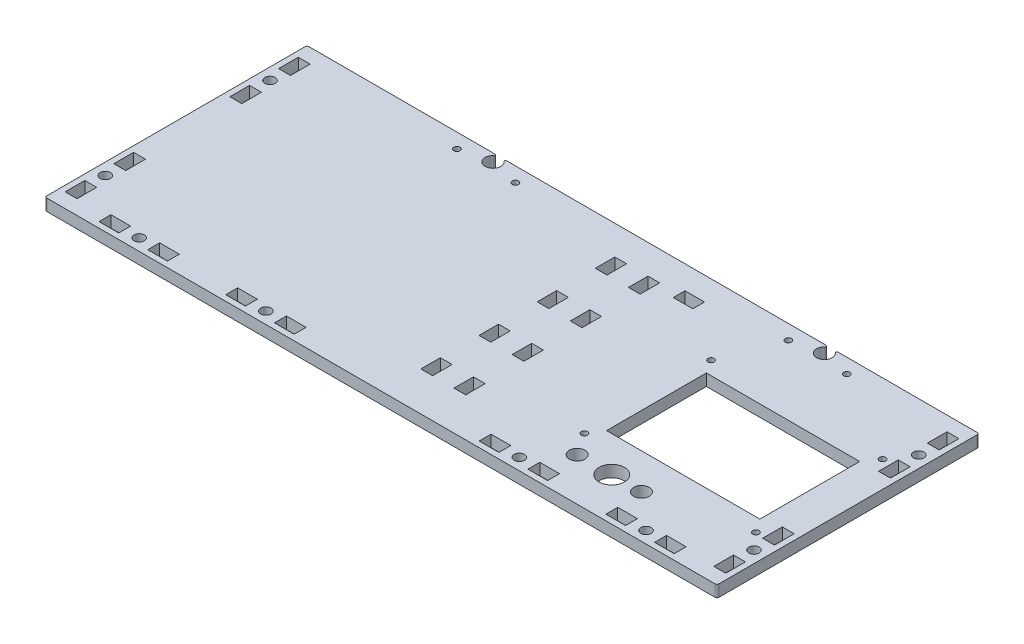
from build123d import *

# Parameters (mm, degrees)
SKETCH1_W                = 344.8
SKETCH1_H                = 134.5
BOSS_EXTRUDE1_DEPTH      = 6
SKETCH2_R                = 6.5
SKETCH2_R_2              = 4
SKETCH2_W                = 78.65
SKETCH2_H                = 51.2
CUT_EXTRUDE1_DEPTH       = 7
M3_CLEARANCE_HOLE1_D     = 3.2
M5_CLEARANCE_HOLE1_D     = 5.3
SKETCH7_W                = 6.1
SKETCH7_H                = 10.1
CUT_EXTRUDE2_DEPTH       = 4
CUT_EXTRUDE2_DEPTH_BACK  = 4
SKETCH71_W               = 6.1
SKETCH71_H               = 10.1
CUT_EXTRUDE21_DEPTH      = 4
CUT_EXTRUDE21_DEPTH_BACK = 4
SKETCH72_W               = 6.1
SKETCH72_H               = 10.1
CUT_EXTRUDE22_DEPTH      = 4
CUT_EXTRUDE22_DEPTH_BACK = 4
SKETCH73_W               = 6.1
SKETCH73_H               = 10.1
CUT_EXTRUDE23_DEPTH      = 4
CUT_EXTRUDE23_DEPTH_BACK = 4
SKETCH74_W               = 6.1
SKETCH74_H               = 10.1
CUT_EXTRUDE24_DEPTH      = 4
CUT_EXTRUDE24_DEPTH_BACK = 4
SKETCH75_W               = 6.1
SKETCH75_H               = 10.1
CUT_EXTRUDE25_DEPTH      = 4
CUT_EXTRUDE25_DEPTH_BACK = 4
SKETCH77_W               = 6.1
SKETCH77_H               = 10.1
CUT_EXTRUDE27_DEPTH      = 4
CUT_EXTRUDE27_DEPTH_BACK = 4
SKETCH78_W               = 6.1
SKETCH78_H               = 10.1
CUT_EXTRUDE28_DEPTH      = 4
CUT_EXTRUDE28_DEPTH_BACK = 4
CUT_EXTRUDE29_DEPTH      = 7
SKETCH62_W               = 10
SKETCH62_H               = 6
CUT_EXTRUDE12_DEPTH      = 4
SKETCH63_W               = 10
SKETCH63_H               = 6
CUT_EXTRUDE13_DEPTH      = 4
SKETCH64_W               = 10
SKETCH64_H               = 6
CUT_EXTRUDE14_DEPTH      = 4
SKETCH65_W               = 10
SKETCH65_H               = 6
CUT_EXTRUDE15_DEPTH      = 4
SKETCH81_R               = 2.65
BOSS_EXTRUDE2_DEPTH      = 6
SKETCH67_W               = 10
SKETCH67_H               = 6
CUT_EXTRUDE17_DEPTH      = 4
CUT_EXTRUDE17_DEPTH_BACK = 4
M3_CLEARANCE_HOLE2_D     = 3.2
FILLET1_R                = 1


with BuildPart() as part:
    # Sketch1 → Boss-Extrude1 (new body)
    with BuildSketch(Plane(origin=(0, 0, 0), x_dir=(1, 0, 0), z_dir=(0, 1, 0))):
        Rectangle(SKETCH1_W, SKETCH1_H)
    extrude(amount=BOSS_EXTRUDE1_DEPTH)

    # Sketch2 → Cut-Extrude1 (cut, through all)
    with BuildSketch(Plane(origin=(0, 0, 0), x_dir=(-1, 0, 0), z_dir=(0, -1, 0))):
        with Locations((-96.4, -45.25)):
            Circle(SKETCH2_R)
        with Locations((-78.65, -45.25)):
            Circle(SKETCH2_R_2)
        with Locations((-111.65, -45.25)):
            Circle(SKETCH2_R_2)
        with Locations((-114.825, -1.4)):
            Rectangle(SKETCH2_W, SKETCH2_H)
    extrude(amount=-CUT_EXTRUDE1_DEPTH, mode=Mode.SUBTRACT)

    # M3 Clearance Hole1 (through all)
    with Locations(Plane(origin=(0, 0, 0), x_dir=(-1, 0, 0), z_dir=(0, -1, 0))):
        with Locations((-159, 31.1), (-71.05, 31.1), (-71.05, -33.9), (-159, -33.9)):
            Hole(M3_CLEARANCE_HOLE1_D / 2)

    # M5 Clearance Hole1 (through all)
    with Locations(Plane(origin=(0, 0, 0), x_dir=(-1, 0, 0), z_dir=(0, -1, 0))):
        with Locations((0, -61.25), (65, -61.25), (130, -61.25), (-166.4, -42.25), (-166.4, 42.25)):
            m5_clearance_hole1 = Hole(M5_CLEARANCE_HOLE1_D / 2)

    # Mirror1: M5 Clearance Hole1 across plane
    add(m5_clearance_hole1.mirror(Plane(origin=(0, 0, 0), x_dir=(0, 0, 1), z_dir=(1, 0, 0))), mode=Mode.SUBTRACT)

    # Sketch7 → Cut-Extrude2 (cut, two sides)
    with BuildSketch(Plane(origin=(122.4, 3, -22.25), x_dir=(1, 0, 0), z_dir=(0, -1, 0))) as cut_extrude2_sk:
        with Locations((44, -32.5)):
            Rectangle(SKETCH7_W, SKETCH7_H)
        with Locations((44, -7.5)):
            Rectangle(SKETCH7_W, SKETCH7_H)
    extrude(amount=CUT_EXTRUDE2_DEPTH, mode=Mode.SUBTRACT)
    extrude(cut_extrude2_sk.sketch, amount=-CUT_EXTRUDE2_DEPTH_BACK, mode=Mode.SUBTRACT)

    # Sketch71 → Cut-Extrude21 (cut, two sides)
    with BuildSketch(Plane(origin=(122.4, 3, 62.25), x_dir=(1, 0, 0), z_dir=(0, -1, 0))) as cut_extrude21_sk:
        with Locations((44, -32.5)):
            Rectangle(SKETCH71_W, SKETCH71_H)
        with Locations((44, -7.5)):
            Rectangle(SKETCH71_W, SKETCH71_H)
    extrude(amount=CUT_EXTRUDE21_DEPTH, mode=Mode.SUBTRACT)
    extrude(cut_extrude21_sk.sketch, amount=-CUT_EXTRUDE21_DEPTH_BACK, mode=Mode.SUBTRACT)

    # Sketch72 → Cut-Extrude22 (cut, two sides)
    with BuildSketch(Plane(origin=(-210.4, 3, -22.25), x_dir=(1, 0, 0), z_dir=(0, -1, 0))) as cut_extrude22_sk:
        with Locations((44, -32.5)):
            Rectangle(SKETCH72_W, SKETCH72_H)
        with Locations((44, -7.5)):
            Rectangle(SKETCH72_W, SKETCH72_H)
    extrude(amount=CUT_EXTRUDE22_DEPTH, mode=Mode.SUBTRACT)
    extrude(cut_extrude22_sk.sketch, amount=-CUT_EXTRUDE22_DEPTH_BACK, mode=Mode.SUBTRACT)

    # Sketch73 → Cut-Extrude23 (cut, two sides)
    with BuildSketch(Plane(origin=(-210.4, 3, 62.25), x_dir=(1, 0, 0), z_dir=(0, -1, 0))) as cut_extrude23_sk:
        with Locations((44, -32.5)):
            Rectangle(SKETCH73_W, SKETCH73_H)
        with Locations((44, -7.5)):
            Rectangle(SKETCH73_W, SKETCH73_H)
    extrude(amount=CUT_EXTRUDE23_DEPTH, mode=Mode.SUBTRACT)
    extrude(cut_extrude23_sk.sketch, amount=-CUT_EXTRUDE23_DEPTH_BACK, mode=Mode.SUBTRACT)

    # Sketch74 → Cut-Extrude24 (cut, two sides)
    with BuildSketch(Plane(origin=(150, 3, 105.25), x_dir=(0, 0, -1), z_dir=(0, -1, 0))) as cut_extrude24_sk:
        with Locations((44, -32.5)):
            Rectangle(SKETCH74_W, SKETCH74_H)
        with Locations((44, -7.5)):
            Rectangle(SKETCH74_W, SKETCH74_H)
    extrude(amount=CUT_EXTRUDE24_DEPTH, mode=Mode.SUBTRACT)
    extrude(cut_extrude24_sk.sketch, amount=-CUT_EXTRUDE24_DEPTH_BACK, mode=Mode.SUBTRACT)

    # Sketch75 → Cut-Extrude25 (cut, two sides)
    with BuildSketch(Plane(origin=(45, 3, 17.25), x_dir=(0, 0, 1), z_dir=(0, -1, 0))) as cut_extrude25_sk:
        with Locations((44, -32.5)):
            Rectangle(SKETCH75_W, SKETCH75_H)
        with Locations((44, -7.5)):
            Rectangle(SKETCH75_W, SKETCH75_H)
    extrude(amount=CUT_EXTRUDE25_DEPTH, mode=Mode.SUBTRACT)
    extrude(cut_extrude25_sk.sketch, amount=-CUT_EXTRUDE25_DEPTH_BACK, mode=Mode.SUBTRACT)

    # Sketch77 → Cut-Extrude27 (cut, two sides)
    with BuildSketch(Plane(origin=(-85, 3, 17.25), x_dir=(0, 0, 1), z_dir=(0, -1, 0))) as cut_extrude27_sk:
        with Locations((44, -32.5)):
            Rectangle(SKETCH77_W, SKETCH77_H)
        with Locations((44, -7.5)):
            Rectangle(SKETCH77_W, SKETCH77_H)
    extrude(amount=CUT_EXTRUDE27_DEPTH, mode=Mode.SUBTRACT)
    extrude(cut_extrude27_sk.sketch, amount=-CUT_EXTRUDE27_DEPTH_BACK, mode=Mode.SUBTRACT)

    # Sketch78 → Cut-Extrude28 (cut, two sides)
    with BuildSketch(Plane(origin=(-150, 3, 17.25), x_dir=(0, 0, 1), z_dir=(0, -1, 0))) as cut_extrude28_sk:
        with Locations((44, -32.5)):
            Rectangle(SKETCH78_W, SKETCH78_H)
        with Locations((44, -7.5)):
            Rectangle(SKETCH78_W, SKETCH78_H)
    extrude(amount=CUT_EXTRUDE28_DEPTH, mode=Mode.SUBTRACT)
    extrude(cut_extrude28_sk.sketch, amount=-CUT_EXTRUDE28_DEPTH_BACK, mode=Mode.SUBTRACT)

    # Sketch79 → Cut-Extrude29 (cut, through all)
    with BuildSketch(Plane(origin=(0, 0, 0), x_dir=(-1, 0, 0), z_dir=(0, -1, 0))):
        with BuildLine():
            Line((-100.023715784, 67.25), (-93.976284216, 67.25))
            ThreePointArc((-93.976284216, 67.25), (-94.5108067, 66.880601937), (-94.354248689, 66.25))
            ThreePointArc((-94.354248689, 66.25), (-97, 59.25), (-99.645751311, 66.25))
            ThreePointArc((-99.645751311, 66.25), (-99.4891933, 66.880601937), (-100.023715784, 67.25))
        make_face()
    cut_extrude29 = extrude(amount=-CUT_EXTRUDE29_DEPTH, mode=Mode.SUBTRACT)

    # Mirror3: Cut-Extrude29 across plane
    add(cut_extrude29.mirror(Plane.ZY.offset(-12)), mode=Mode.SUBTRACT)

    # Sketch62 → Cut-Extrude12 (cut, symmetric)
    with BuildSketch(Plane(origin=(-40.5, 3, 41.482221392), x_dir=(0, 0, 1), z_dir=(0, -1, 0))):
        with Locations((0.767778608, -44)):
            Rectangle(SKETCH62_W, SKETCH62_H)
    cut_extrude12 = extrude(amount=CUT_EXTRUDE12_DEPTH, both=True, mode=Mode.SUBTRACT)

    # Sketch63 → Cut-Extrude13 (cut, symmetric)
    with BuildSketch(Plane(origin=(-40.5, 3, 11.648888059), x_dir=(0, 0, 1), z_dir=(0, -1, 0))):
        with Locations((0.767778608, -44)):
            Rectangle(SKETCH63_W, SKETCH63_H)
    cut_extrude13 = extrude(amount=CUT_EXTRUDE13_DEPTH, both=True, mode=Mode.SUBTRACT)

    # Sketch64 → Cut-Extrude14 (cut, symmetric)
    with BuildSketch(Plane(origin=(-40.5, 3, -18.184445274), x_dir=(0, 0, 1), z_dir=(0, -1, 0))):
        with Locations((0.767778608, -44)):
            Rectangle(SKETCH64_W, SKETCH64_H)
    cut_extrude14 = extrude(amount=CUT_EXTRUDE14_DEPTH, both=True, mode=Mode.SUBTRACT)

    # Sketch65 → Cut-Extrude15 (cut, symmetric)
    with BuildSketch(Plane(origin=(-40.5, 3, -48.017778608), x_dir=(0, 0, 1), z_dir=(0, -1, 0))):
        with Locations((0.767778608, -44)):
            Rectangle(SKETCH65_W, SKETCH65_H)
    cut_extrude15 = extrude(amount=CUT_EXTRUDE15_DEPTH, both=True, mode=Mode.SUBTRACT)

    # Mirror2: Cut-Extrude12, Cut-Extrude13, Cut-Extrude14, Cut-Extrude15 across plane
    add(cut_extrude12.mirror(Plane(origin=(12, 0, 0), x_dir=(0, 0, 1), z_dir=(1, 0, 0))), mode=Mode.SUBTRACT)
    add(cut_extrude13.mirror(Plane(origin=(12, 0, 0), x_dir=(0, 0, 1), z_dir=(1, 0, 0))), mode=Mode.SUBTRACT)
    add(cut_extrude14.mirror(Plane(origin=(12, 0, 0), x_dir=(0, 0, 1), z_dir=(1, 0, 0))), mode=Mode.SUBTRACT)
    add(cut_extrude15.mirror(Plane(origin=(12, 0, 0), x_dir=(0, 0, 1), z_dir=(1, 0, 0))), mode=Mode.SUBTRACT)

    # Sketch81 → Boss-Extrude2 (add, through all)
    with BuildSketch(Plane.XZ):
        with Locations((0, 61.25)):
            Circle(SKETCH81_R)
    extrude(amount=-BOSS_EXTRUDE2_DEPTH)

    # Sketch67 → Cut-Extrude17 (cut, two sides)
    with BuildSketch(Plane(origin=(37.732221392, 3, -8.25), x_dir=(1, 0, 0), z_dir=(0, -1, 0))) as cut_extrude17_sk:
        with Locations((0.767778608, -44)):
            Rectangle(SKETCH67_W, SKETCH67_H)
    extrude(amount=CUT_EXTRUDE17_DEPTH, mode=Mode.SUBTRACT)
    extrude(cut_extrude17_sk.sketch, amount=-CUT_EXTRUDE17_DEPTH_BACK, mode=Mode.SUBTRACT)

    # M3 Clearance Hole2 (through all)
    with Locations(Plane(origin=(0, 0, 0), x_dir=(-1, 0, 0), z_dir=(0, -1, 0))):
        with Locations((-112, 59.75), (-82, 59.75), (58, 59.75), (88, 59.75)):
            Hole(M3_CLEARANCE_HOLE2_D / 2)

    # Fillet1
    fillet1_edges = [part.edges().sort_by_distance(p)[0] for p in [
        (172.4, 3, 67.25),
        (-172.4, 3, 67.25),
        (-172.4, 3, -67.25),
        (172.4, 3, -67.25),
    ]]
    fillet(fillet1_edges, radius=FILLET1_R)


solid = part.part
